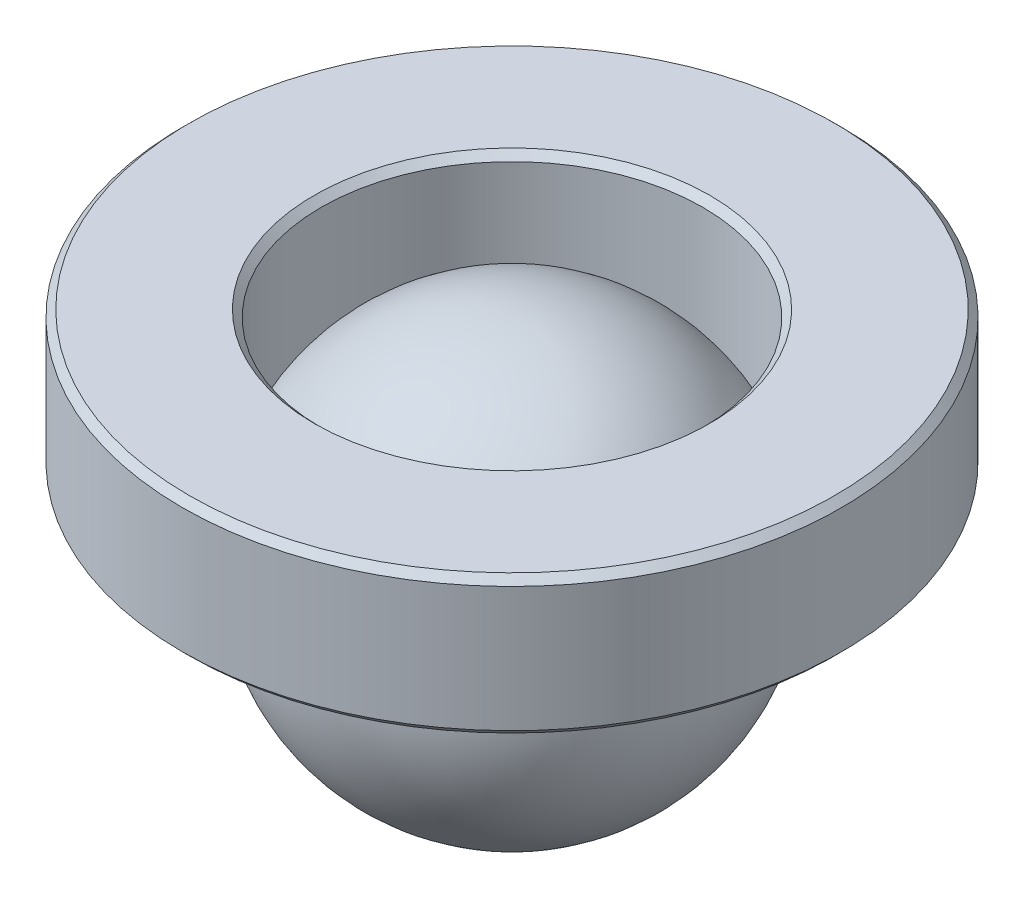
from build123d import *


with BuildPart() as part:
    # Croquis1 → Revolución1 (revolve)
    with BuildSketch(Plane.XY):
        Polygon((-2.85, 1.098957881), (-2.75, 1.198957881), (-2.75, 2.998957881), (-2.85, 3.098957881), (-4.65, 3.098957881), (-4.75, 2.998957881), (-4.75, 1.198957881), (-4.65, 1.098957881), align=None)
    revolve(axis=Axis((0, 3, 0), (0, -1, 0)))


with BuildPart() as body_2:
    # Croquis2 → Revolución2 (revolve)
    with BuildSketch(Plane.XY):
        with BuildLine():
            Line((0, 3), (0, -3))
            ThreePointArc((0, -3), (-3, 0), (0, 3))
        make_face()
    revolve(axis=Axis((0, 3, 0), (0, -1, 0)))


solid = Compound([part.part, body_2.part])
